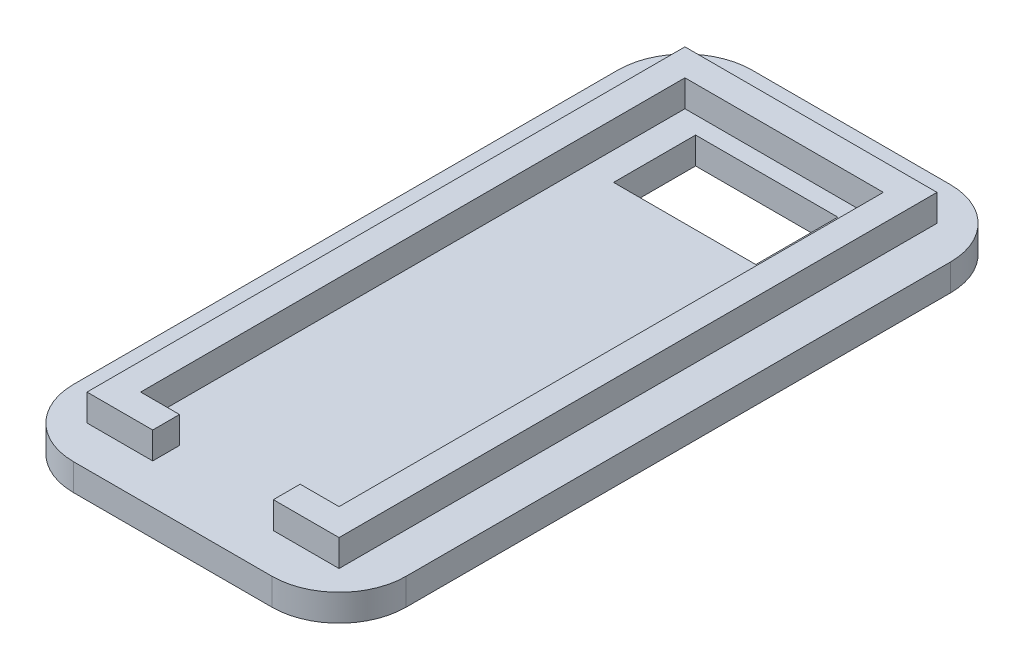
from build123d import *

# Parameters (mm, degrees)
SKETCH1_W           = 24.8
SKETCH1_H           = 50.6
BOSS_EXTRUDE1_DEPTH = 2
BOSS_EXTRUDE2_DEPTH = 2
SKETCH3_W           = 10.61
SKETCH3_H           = 6.12
CUT_EXTRUDE1_DEPTH  = 3
FILLET1_R           = 5


with BuildPart() as part:
    # Sketch1 → Boss-Extrude1 (new body)
    with BuildSketch(Plane(origin=(0, 0, 0), x_dir=(1, 0, 0), z_dir=(0, 1, 0))):
        Rectangle(SKETCH1_W, SKETCH1_H)
    extrude(amount=BOSS_EXTRUDE1_DEPTH)

    # Sketch2 → Boss-Extrude2 (add)
    with BuildSketch(Plane(origin=(0, 2, 0), x_dir=(1, 0, 0), z_dir=(0, 1, 0))):
        Polygon((-7.4, 20.3), (7.4, 20.3), (7.4, -20.3), (4.5, -20.3), (4.5, -22.3), (9.4, -22.3), (9.4, 22.3), (-9.4, 22.3), (-9.4, -22.3), (-4.5, -22.3), (-4.5, -20.3), (-7.4, -20.3), align=None)
    extrude(amount=BOSS_EXTRUDE2_DEPTH)

    # Sketch3 → Cut-Extrude1 (cut, through all)
    with BuildSketch(Plane(origin=(0, 2, 0), x_dir=(1, 0, 0), z_dir=(0, 1, 0))):
        with Locations((0, 15.94)):
            Rectangle(SKETCH3_W, SKETCH3_H)
    extrude(amount=-CUT_EXTRUDE1_DEPTH, mode=Mode.SUBTRACT)

    # Fillet1
    fillet1_edges = [part.edges().sort_by_distance(p)[0] for p in [
        (12.4, 1, -25.3),
        (12.4, 1, 25.3),
        (-12.4, 1, 25.3),
        (-12.4, 1, -25.3),
    ]]
    fillet(fillet1_edges, radius=FILLET1_R)


solid = part.part
